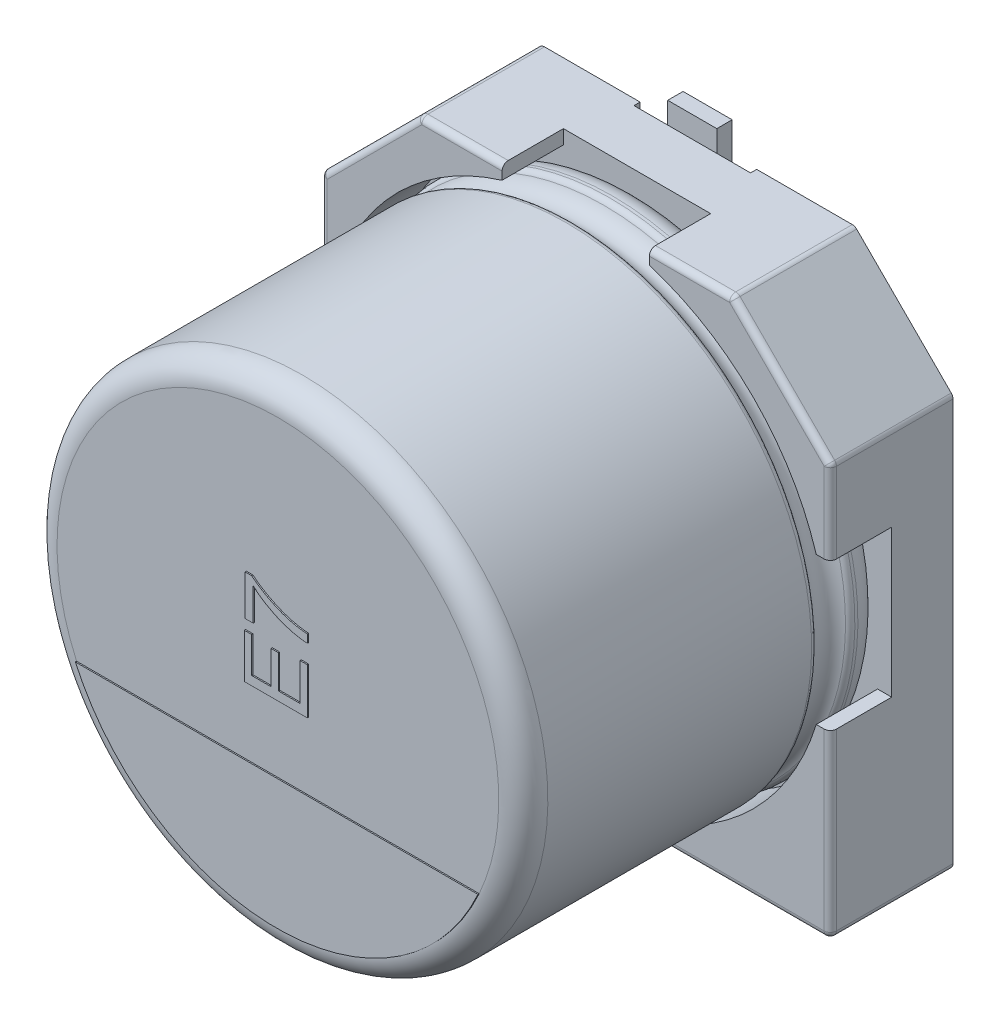
from build123d import *

# Parameters (mm, degrees)
BOSS_EXTRUDE1_DEPTH  = 1
BOSS_EXTRUDE2_DEPTH  = 1
SKETCH7_R            = 0.35
SPACER_PAD_DEPTH     = 0.15
SKETCH9_W            = 1.9
SKETCH9_H            = 2.65
CUT_EXTRUDE1_DEPTH   = 0.1
FILLET1_R            = 0.1
FILLET2_R            = 0.1
CATHODE_MARKER_DEPTH = 0.02
TEXT_2_DEPTH         = 0.02
SKETCH19_W           = 0.8
SKETCH19_H           = 2.9
BOSS_EXTRUDE6_DEPTH  = 0.25


with BuildPart() as part:
    # Sketch2 → Boss-Extrude1 (new body)
    with BuildSketch(Plane.XY):
        Polygon((-4.15, 2.55), (-2.55, 4.15), (2.55, 4.15), (4.15, 2.55), (4.15, -4.15), (-4.15, -4.15), align=None)
    extrude(amount=BOSS_EXTRUDE1_DEPTH)

    # Sketch4 → Boss-Extrude2 (add)
    with BuildSketch(Plane.XY.offset(1)):
        with BuildLine():
            Line((-4.15, 2.55), (-2.55, 4.15))
            Line((-2.55, 4.15), (-1.2, 4.15))
            Line((-1.2, 4.15), (-1.2, 3.920459157))
            ThreePointArc((-1.2, 3.920459157), (-2.899137803, 2.899137803), (-3.920459157, 1.2))
            Line((-3.920459157, 1.2), (-4.15, 1.2))
            Line((-4.15, 1.2), (-4.15, 2.55))
        make_face()
        with BuildLine():
            Line((2.55, 4.15), (4.15, 2.55))
            Line((4.15, 2.55), (4.15, 1.2))
            Line((4.15, 1.2), (3.920459157, 1.2))
            ThreePointArc((3.920459157, 1.2), (2.899137803, 2.899137803), (1.2, 3.920459157))
            Line((1.2, 3.920459157), (1.2, 4.15))
            Line((1.2, 4.15), (2.55, 4.15))
        make_face()
        with BuildLine():
            Line((4.15, -1.2), (4.15, -4.15))
            Line((4.15, -4.15), (1.2, -4.15))
            Line((1.2, -4.15), (1.2, -3.920459157))
            ThreePointArc((1.2, -3.920459157), (2.899137803, -2.899137803), (3.920459157, -1.2))
            Line((3.920459157, -1.2), (4.15, -1.2))
        make_face()
        with BuildLine():
            Line((-4.15, -1.2), (-4.15, -4.15))
            Line((-4.15, -4.15), (-1.2, -4.15))
            Line((-1.2, -4.15), (-1.2, -3.920459157))
            ThreePointArc((-1.2, -3.920459157), (-2.899137803, -2.899137803), (-3.920459157, -1.2))
            Line((-3.920459157, -1.2), (-4.15, -1.2))
        make_face()
    extrude(amount=BOSS_EXTRUDE2_DEPTH)

    # Sketch7 → Spacer Pad (add)
    with BuildSketch(Plane(origin=(0, 0, 0), x_dir=(1, 0, 0), z_dir=(0, 0, -1))):
        with Locations((-2.906501466, 2.844859418)):
            Circle(SKETCH7_R)
        with Locations((2.906501466, 2.844859418)):
            Circle(SKETCH7_R)
        with Locations((-2.906501466, -2.844859418)):
            Circle(SKETCH7_R)
        with Locations((2.906501466, -2.844859418)):
            Circle(SKETCH7_R)
    extrude(amount=SPACER_PAD_DEPTH)

    # Sketch9 → Cut-Extrude1 (cut)
    with BuildSketch(Plane(origin=(0, 0, 0), x_dir=(1, 0, 0), z_dir=(0, 0, -1))):
        with Locations((0, 2.825)):
            Rectangle(SKETCH9_W, SKETCH9_H)
        with Locations((0, -2.825)):
            Rectangle(SKETCH9_W, SKETCH9_H)
    extrude(amount=-CUT_EXTRUDE1_DEPTH, mode=Mode.SUBTRACT)

    # Fillet1
    fillet1_edges = [part.edges().sort_by_distance(p)[0] for p in [
        (4.15, -4.15, 1),
        (-4.15, -4.15, 1),
        (-4.15, 2.55, 1),
        (-2.55, 4.15, 1),
        (2.55, 4.15, 1),
        (4.15, 2.55, 1),
    ]]
    fillet(fillet1_edges, radius=FILLET1_R)

    # Sketch10 → Revolve1 (revolve)
    with BuildSketch(Plane(origin=(0, 0, 0), x_dir=(0, 0, -1), z_dir=(1, 0, 0))):
        with BuildLine():
            Line((-6.853626625, 0), (-1, 0))
            Line((-1, 0), (-1, 3.6))
            ThreePointArc((-1, 3.6), (-1.117157288, 3.882842712), (-1.4, 4))
            Line((-1.4, 4), (-1.449422929, 4))
            ThreePointArc((-1.449422929, 4), (-1.504479696, 3.983479053), (-1.541344666, 3.939375046))
            ThreePointArc((-1.541344666, 3.939375046), (-1.801990181, 3.767472047), (-2.062635697, 3.939375046))
            ThreePointArc((-2.062635697, 3.939375046), (-2.099500666, 3.983479053), (-2.154557434, 4))
            Line((-2.154557434, 4), (-6.453626625, 4))
            ThreePointArc((-6.453626625, 4), (-6.736469337, 3.882842712), (-6.853626625, 3.6))
            Line((-6.853626625, 3.6), (-6.853626625, 0))
        make_face()
    revolve(axis=Axis((0, 0, -18.9630778), (0, 0, 1)))

    # Fillet2
    fillet2_edges = [part.edges().sort_by_distance(p)[0] for p in [
        (2.625, -4.15, 2),
        (4.120710678, -4.120710678, 2),
        (4.15, 1.854289322, 2),
        (4.142387953, 2.546846987, 2),
        (1.854289322, 4.15, 2),
        (2.546846987, 4.142387953, 2),
        (-1.854289322, 4.15, 2),
        (-2.546846987, 4.142387953, 2),
        (-3.35, 3.35, 2),
        (-4.142387953, 2.546846987, 2),
        (-4.15, -2.625, 2),
        (-4.120710678, -4.120710678, 2),
        (4.15, -2.625, 2),
        (3.35, 3.35, 2),
        (-4.15, 1.854289322, 2),
        (-2.625, -4.15, 2),
    ]]
    fillet(fillet2_edges, radius=FILLET2_R)

    # Sketch13 → Cathode marker (add)
    with BuildSketch(Plane.XY.offset(6.853626625)):
        with BuildLine():
            Line((-3.280894476, -1.481800067), (3.280894476, -1.481800067))
            ThreePointArc((3.280894476, -1.481800067), (0, -3.6), (-3.280894476, -1.481800067))
        make_face()
    extrude(amount=CATHODE_MARKER_DEPTH)

    # Sketch15 → Text 2 (add)
    with BuildSketch(Plane.XY.offset(6.853626625)):
        Polygon((0.5, -0.381462215), (-0.527327474, -0.381462215), (-0.527327474, 0.342935363), (-0.408789689, 0.342935363), (-0.408789689, -0.236582699), (-0.092688927, -0.236582699), (-0.092688927, 0.303422768), (0.025848858, 0.303422768), (0.025848858, -0.236582699), (0.381462215, -0.236582699), (0.381462215, 0.369277093), (0.5, 0.369277093), align=None)
        with BuildLine():
            Line((-0.382447958, 0.514156609), (-0.514156609, 0.514156609))
            Line((-0.514156609, 0.514156609), (-0.514156609, 1.172699861))
            Line((-0.514156609, 1.172699861), (-0.40755492, 1.172699861))
            add(Edge.make_bspline(
                [(-0.40755492, 1.172699861), (-0.398488677, 1.164947127), (-0.379951395, 1.14909551), (-0.350424936, 1.126130467), (-0.318987397, 1.103049241), (-0.285346017, 1.080241898), (-0.24975787, 1.057461693), (-0.212211651, 1.034519228), (-0.17255254, 1.011727663), (-0.116955171, 0.981669045), (-0.045699914, 0.945988553), (0.041981636, 0.9087322), (0.130508424, 0.875729648), (0.190710422, 0.858159494), (0.220736502, 0.849396283)],
                knots=[0, 0, 0, 0, 0.6032745, 1.233484441, 1.891357215, 2.57557336, 3.288734553, 4.028369461, 4.800843345, 5.601920993, 7.224937043, 8.829018402, 10.418455404, 12, 12, 12, 12], degree=3))
            add(Edge.make_bspline(
                [(0.220736502, 0.849396283), (0.242421638, 0.843713465), (0.286537257, 0.832152502), (0.355043228, 0.819496809), (0.42647102, 0.809712082), (0.475211113, 0.805869799), (0.5, 0.80391564)],
                knots=[0, 0, 0, 0, 0.948866074, 1.930345965, 2.947387709, 4, 4, 4, 4], degree=3))
            Line((0.5, 0.80391564), (0.5, 0.67220699))
            add(Edge.make_bspline(
                [(0.5, 0.67220699), (0.489773475, 0.672522901), (0.46874323, 0.673172553), (0.436428019, 0.676045369), (0.402506992, 0.679871697), (0.36709474, 0.685276058), (0.330119386, 0.692145455), (0.291541741, 0.700331204), (0.251441688, 0.710107529), (0.19584519, 0.724565393), (0.125940112, 0.746043249), (0.043270268, 0.777287108), (-0.037987002, 0.813338585), (-0.103991595, 0.847429493), (-0.155181852, 0.876894883), (-0.192377433, 0.899031609), (-0.227842847, 0.921879171), (-0.261816887, 0.944922195), (-0.294319185, 0.968180532), (-0.325048234, 0.99212388), (-0.354620783, 1.016047349), (-0.373254036, 1.032749917), (-0.382447958, 1.040991211)],
                knots=[0, 0, 0, 0, 0.630310263, 1.296195935, 1.998233977, 2.733510572, 3.502865957, 4.315300234, 5.16313825, 6.045860881, 7.854817038, 9.665969389, 11.488229695, 13.329548187, 14.240214963, 15.127489952, 15.996309606, 16.839233987, 17.656863512, 18.458360632, 19.239332369, 20, 20, 20, 20], degree=3))
            Line((-0.382447958, 1.040991211), (-0.382447958, 0.514156609))
        make_face()
    extrude(amount=TEXT_2_DEPTH)

    # Sketch19 → Boss-Extrude6 (add)
    with BuildSketch(Plane(origin=(0, 0, 0.1), x_dir=(1, 0, 0), z_dir=(0, 0, -1))):
        with Locations((0, 3.05)):
            Rectangle(SKETCH19_W, SKETCH19_H)
        with Locations((0, -3.05)):
            Rectangle(SKETCH19_W, SKETCH19_H)
    extrude(amount=BOSS_EXTRUDE6_DEPTH)


solid = part.part
